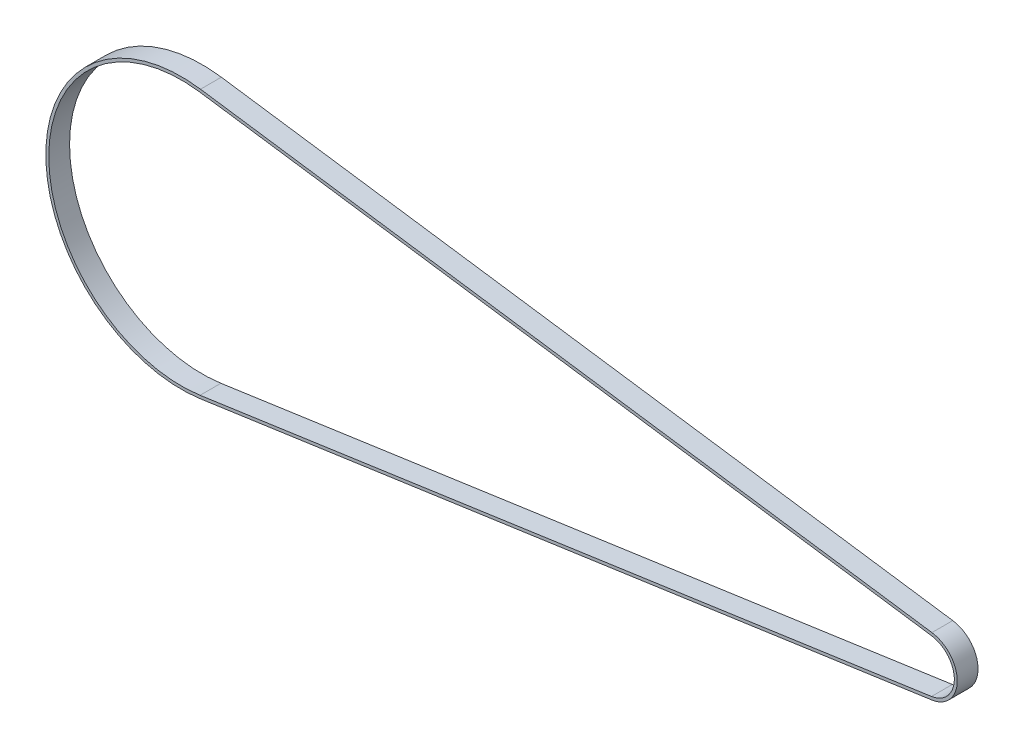
from build123d import *

# Parameters (mm, degrees)
EXTRUDE_THIN1_DEPTH = 14.224


with BuildPart() as part:
    # Sketch2 → Extrude-Thin1 (new body)
    with BuildSketch(Plane.XY):
        with BuildLine():
            Line((-496.863202176, 91.613929858), (2.861676059, 19.956871777))
            ThreePointArc((2.861676059, 19.956871777), (20.161, 0), (2.861676059, -19.956871777))
            Line((2.861676059, -19.956871777), (-496.863202176, -91.613929858))
            ThreePointArc((-496.863202176, -91.613929858), (-602.551, 0), (-496.863202176, 91.613929858))
        make_face()
        with BuildLine():
            Line((-497.147084529, 89.634179669), (2.577793706, 17.977121589))
            ThreePointArc((2.577793706, 17.977121589), (18.161, 0), (2.577793706, -17.977121589))
            Line((2.577793706, -17.977121589), (-497.147084529, -89.634179669))
            ThreePointArc((-497.147084529, -89.634179669), (-600.551, 0), (-497.147084529, 89.634179669))
        make_face(mode=Mode.SUBTRACT)
    extrude(amount=EXTRUDE_THIN1_DEPTH)


solid = part.part
